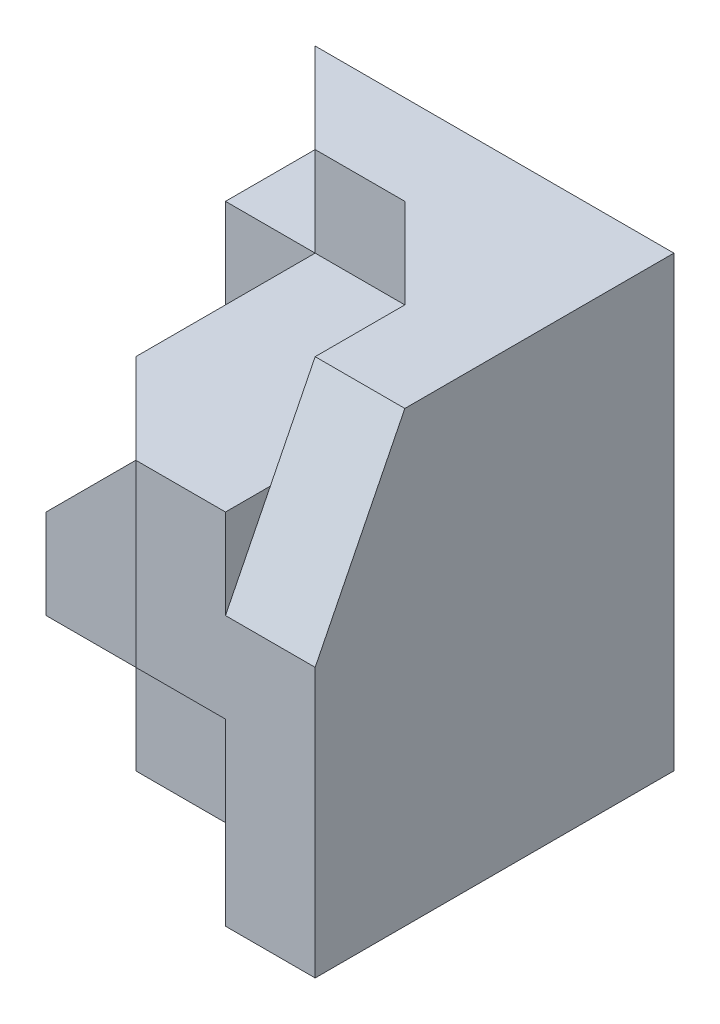
from build123d import *

# Parameters (mm, degrees)
SKETCH1_W           = 40
SKETCH1_H           = 40
BOSS_EXTRUDE1_DEPTH = 50
CUT_EXTRUDE1_DEPTH  = 10
CUT_EXTRUDE2_DEPTH  = 10
CUT_EXTRUDE5_DEPTH  = 10
CUT_EXTRUDE6_DEPTH  = 30
CUT_EXTRUDE7_DEPTH  = 10
SKETCH10_W          = 10
SKETCH10_H          = 10
CUT_EXTRUDE8_DEPTH  = 10
SKETCH11_W          = 30
SKETCH11_H          = 20
CUT_EXTRUDE9_DEPTH  = 10
SKETCH13_W          = 10
SKETCH13_H          = 10
CUT_EXTRUDE10_DEPTH = 31


with BuildPart() as part:
    # Sketch1 → Boss-Extrude1 (new body)
    with BuildSketch(Plane(origin=(0, 0, 0), x_dir=(1, 0, 0), z_dir=(0, 1, 0))):
        Rectangle(SKETCH1_W, SKETCH1_H)
    extrude(amount=BOSS_EXTRUDE1_DEPTH)

    # Sketch2 → Cut-Extrude1 (cut)
    with BuildSketch(Plane(origin=(0, 50, 0), x_dir=(1, 0, 0), z_dir=(0, 1, 0))):
        Polygon((-20, 20), (-10, 10), (0, 10), (10, 0), (10, -20), (-20, -20), align=None)
    extrude(amount=-CUT_EXTRUDE1_DEPTH, mode=Mode.SUBTRACT)

    # Sketch3 → Cut-Extrude2 (cut)
    with BuildSketch(Plane(origin=(20, 0, 0), x_dir=(0, 0, -1), z_dir=(1, 0, 0))):
        Polygon((-20, 50), (-10, 50), (-20, 30), align=None)
    extrude(amount=-CUT_EXTRUDE2_DEPTH, mode=Mode.SUBTRACT)

    # Sketch7 → Cut-Extrude5 (cut)
    with BuildSketch(Plane(origin=(0, 40, 0), x_dir=(1, 0, 0), z_dir=(0, 1, 0))):
        Polygon((0, -20), (-10, -10), (-10, 10), (-20, 10), (-20, -20), align=None)
    extrude(amount=-CUT_EXTRUDE5_DEPTH, mode=Mode.SUBTRACT)

    # Sketch8 → Cut-Extrude6 (cut)
    with BuildSketch(Plane.XY.offset(20)):
        Polygon((-10, 30), (-20, 20), (-20, 30), align=None)
    extrude(amount=-CUT_EXTRUDE6_DEPTH, mode=Mode.SUBTRACT)

    # Sketch9 → Cut-Extrude7 (cut)
    with BuildSketch(Plane(origin=(0, 30, 0), x_dir=(1, 0, 0), z_dir=(0, 1, 0))):
        Polygon((0, -20), (-10, -10), (-10, -20), align=None)
    extrude(amount=-CUT_EXTRUDE7_DEPTH, mode=Mode.SUBTRACT)

    # Sketch10 → Cut-Extrude8 (cut)
    with BuildSketch(Plane(origin=(-10, 0, 0), x_dir=(0, 0, -1), z_dir=(1, 0, 0))):
        with Locations((-15, 25)):
            Rectangle(SKETCH10_W, SKETCH10_H)
    extrude(amount=-CUT_EXTRUDE8_DEPTH, mode=Mode.SUBTRACT)

    # Sketch11 → Cut-Extrude9 (cut)
    with BuildSketch(Plane.XY.offset(20)):
        with Locations((-5, 10)):
            Rectangle(SKETCH11_W, SKETCH11_H)
    extrude(amount=-CUT_EXTRUDE9_DEPTH, mode=Mode.SUBTRACT)

    # Sketch13 → Cut-Extrude10 (cut, through all)
    with BuildSketch(Plane.XY.offset(10)):
        with Locations((-15, 5)):
            Rectangle(SKETCH13_W, SKETCH13_H)
    extrude(amount=-CUT_EXTRUDE10_DEPTH, mode=Mode.SUBTRACT)


solid = part.part
